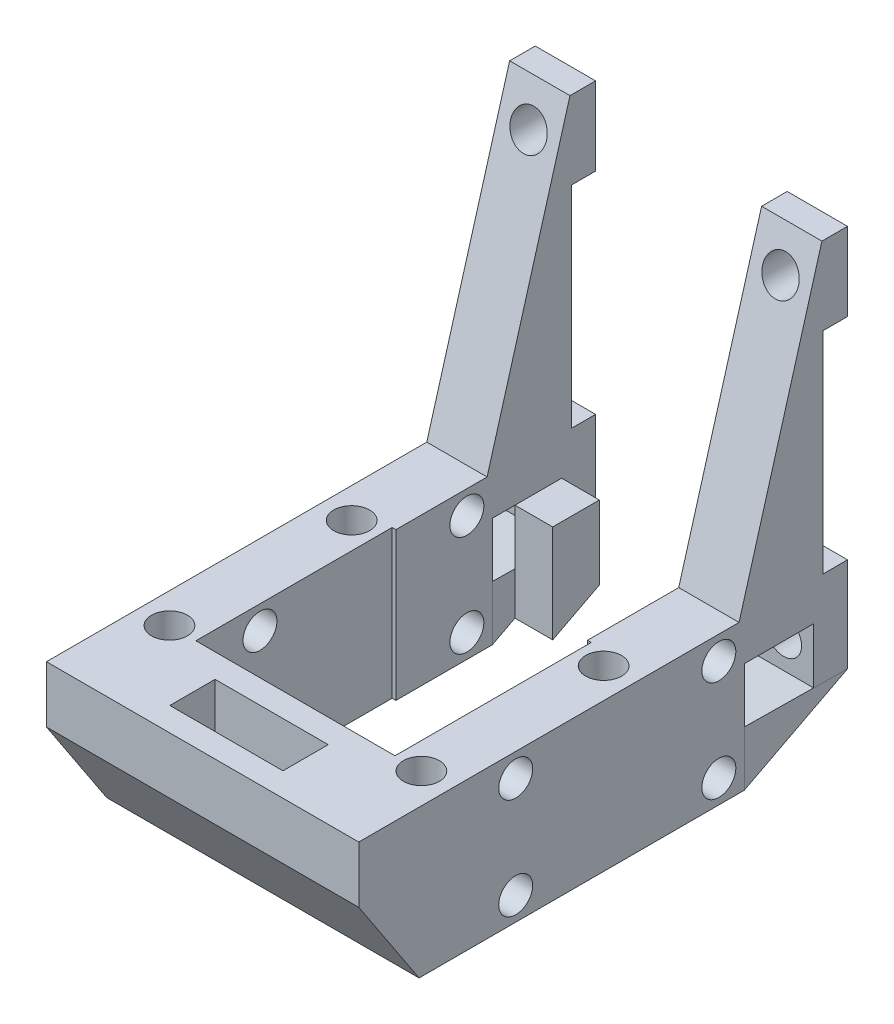
from build123d import *

# Parameters (mm, degrees)
SKETCH1_W             = 7.5
SKETCH1_H             = 7.5
BOSS_EXTRUDE1_DEPTH   = 5.5
BOSS_EXTRUDE1_2_DEPTH = 5.5
BOSS_EXTRUDE1_3_DEPTH = 5.5
BOSS_EXTRUDE1_4_DEPTH = 5.5
BOSS_EXTRUDE2_START   = -5.5
SKETCH2_W             = 8
SKETCH2_H             = 7.5
BOSS_EXTRUDE2_DEPTH   = 50.5
SKETCH3_W             = 41.4
SKETCH3_H             = 7.5
BOSS_EXTRUDE3_DEPTH   = 16
BOSS_EXTRUDE4_DEPTH   = 8
SKETCH5_R             = 2.5
CUT_EXTRUDE1_DEPTH    = 8
SKETCH6_W             = 38.1096
SKETCH6_H             = 12.112327922
BOSS_EXTRUDE6_DEPTH   = 8
SKETCH9_W             = 41.4
SKETCH9_H             = 12.112327922
BOSS_EXTRUDE7_DEPTH   = 8
SKETCH10_R            = 2.25
CUT_EXTRUDE2_DEPTH    = 42.4
BOSS_EXTRUDE8_DEPTH   = 8
BOSS_EXTRUDE9_DEPTH   = 8
SKETCH13_W            = 4.925533285
SKETCH13_H            = 27.926
CUT_EXTRUDE3_DEPTH    = 42.4
BOSS_EXTRUDE10_DEPTH  = 41.4
SKETCH16_W            = 26.4
SKETCH16_H            = 26.013663936
CUT_EXTRUDE5_DEPTH    = 20.612327922
SKETCH17_W            = 25.4
SKETCH17_H            = 5.5
CUT_EXTRUDE6_DEPTH    = 50
SKETCH18_W            = 41.4
SKETCH18_H            = 1.703308899
CUT_EXTRUDE7_DEPTH    = 50
SKETCH19_R            = 2.38125
CUT_EXTRUDE8_DEPTH    = 50
SKETCH21_W            = 10.687091101
SKETCH21_H            = 14.528220305
CUT_EXTRUDE10_DEPTH   = 55
SKETCH22_W            = 8
SKETCH22_H            = 4.5
BOSS_EXTRUDE11_DEPTH  = 7.42786537
SKETCH23_R            = 2.38125
CUT_EXTRUDE11_DEPTH   = 5
SKETCH25_W            = 6.187091101
SKETCH25_H            = 14.528220305
BOSS_EXTRUDE12_DEPTH  = 5
SKETCH26_W            = 3
SKETCH26_H            = 14.528220305
CUT_EXTRUDE12_DEPTH   = 42.4
BOSS_EXTRUDE15_DEPTH  = 8
CUT_EXTRUDE13_DEPTH   = 34.4
SKETCH29_W            = 15
SKETCH29_H            = 6
CUT_EXTRUDE14_DEPTH   = 10
SKETCH30_R            = 2.38125
CUT_EXTRUDE15_DEPTH   = 10
SKETCH31_R            = 2.38125
CUT_EXTRUDE16_DEPTH   = 10


with BuildPart() as part:
    # Sketch1 → Boss-Extrude1 (new body)
    with BuildSketch(Plane(origin=(-474.147028746, -1016.113518437, 5527.294851894), x_dir=(1, 0, 0), z_dir=(0, 0, 1))):
        with Locations((215.351694909, 679.332213979)):
            Rectangle(SKETCH1_W, SKETCH1_H)
    extrude(amount=BOSS_EXTRUDE1_DEPTH)

    # Sketch2 → Boss-Extrude2 (add)
    with BuildSketch(Plane.XY.offset(5532.794851894).offset(BOSS_EXTRUDE2_START)):
        with Locations((-233.145333837, -336.781304458)):
            Rectangle(SKETCH2_W, SKETCH2_H)
        with Locations((-266.545333837, -336.781304458)):
            Rectangle(SKETCH2_W, SKETCH2_H)
    boss_extrude2 = extrude(amount=BOSS_EXTRUDE2_DEPTH)

    # Sketch3 → Boss-Extrude3 (add)
    with BuildSketch(Plane.XY.offset(5577.794851894)):
        with Locations((-249.845333837, -336.781304458)):
            Rectangle(SKETCH3_W, SKETCH3_H)
    extrude(amount=BOSS_EXTRUDE3_DEPTH)



with BuildPart() as body_2:
    # Sketch1 → Boss-Extrude1 2 (new body)
    with BuildSketch(Plane(origin=(-474.147028746, -1016.113518437, 5527.294851894), x_dir=(1, 0, 0), z_dir=(0, 0, 1))):
        with Locations((233.251694909, 679.332213979)):
            Rectangle(SKETCH1_W, SKETCH1_H)
    extrude(amount=BOSS_EXTRUDE1_2_DEPTH)


with BuildPart() as body_3:
    # Sketch1 → Boss-Extrude1 3 (new body)
    with BuildSketch(Plane(origin=(-474.147028746, -1016.113518437, 5527.294851894), x_dir=(1, 0, 0), z_dir=(0, 0, 1))):
        with Locations((233.251694909, 714.758213979)):
            Rectangle(SKETCH1_W, SKETCH1_H)
    extrude(amount=BOSS_EXTRUDE1_3_DEPTH)


with BuildPart() as body_4:
    # Sketch1 → Boss-Extrude1 4 (new body)
    with BuildSketch(Plane(origin=(-474.147028746, -1016.113518437, 5527.294851894), x_dir=(1, 0, 0), z_dir=(0, 0, 1))):
        with Locations((215.351694909, 714.758213979)):
            Rectangle(SKETCH1_W, SKETCH1_H)
    extrude(amount=BOSS_EXTRUDE1_4_DEPTH)


with BuildPart() as part_1:
    add(part.part)

    add(body_4.part)  # Boss-Extrude4 merges body 4
    # Sketch4 → Boss-Extrude4 (add)
    with BuildSketch(Plane.ZY.offset(262.545333837)):
        Polygon((5527.294851894, -333.031304458), (5527.294851894, -294.74397633), (5532.394065696, -294.74397633), (5543.378858785, -333.031304458), align=None)
    boss_extrude4 = extrude(amount=BOSS_EXTRUDE4_DEPTH)

    # Mirror1: Boss-Extrude2, Boss-Extrude4 across plane
    add(boss_extrude2.mirror(Plane.ZY.offset(249.845333837)))
    add(boss_extrude4.mirror(Plane.ZY.offset(249.845333837)))


with BuildPart() as cut_extrude1_tool:
    # Sketch5 → Cut-Extrude1 (new body)
    with BuildSketch(Plane.XY.offset(5532.794851894)):
        with Locations((-258.795333837, -301.355304458)):
            Circle(SKETCH5_R)
        with Locations((-240.895333837, -301.355304458)):
            Circle(SKETCH5_R)
        with Locations((-240.895333837, -336.781304458)):
            Circle(SKETCH5_R)
        with Locations((-258.795333837, -336.781304458)):
            Circle(SKETCH5_R)
    extrude(amount=-CUT_EXTRUDE1_DEPTH)


with BuildPart() as part_2:
    add(part_1.part)

    # Cut-Extrude1: cut by cut_extrude1_tool
    add(cut_extrude1_tool.part, mode=Mode.SUBTRACT)

    # Sketch6 → Boss-Extrude6 (add)
    with BuildSketch(Plane.ZY.offset(270.545333837)):
        with Locations((5558.740051894, -346.587468419)):
            Rectangle(SKETCH6_W, SKETCH6_H)
    boss_extrude6 = extrude(amount=-BOSS_EXTRUDE6_DEPTH)

    # Mirror2: Boss-Extrude6 across plane
    add(boss_extrude6.mirror(Plane.ZY.offset(249.845333837)))

    # Sketch9 → Boss-Extrude7 (add)
    with BuildSketch(Plane.XY.offset(5577.794851894)):
        with Locations((-249.845333837, -346.587468419)):
            Rectangle(SKETCH9_W, SKETCH9_H)
    extrude(amount=BOSS_EXTRUDE7_DEPTH)

    # Sketch10 → Cut-Extrude2 (cut, through all)
    with BuildSketch(Plane.ZY.offset(270.545333837)):
        with Locations((5546.061207304, -349.537271609)):
            Circle(SKETCH10_R)
        with Locations((5572.989599872, -349.537271609)):
            Circle(SKETCH10_R)
        with Locations((5546.061207304, -336.137665229)):
            Circle(SKETCH10_R)
        with Locations((5572.989599872, -336.137665229)):
            Circle(SKETCH10_R)
    extrude(amount=-CUT_EXTRUDE2_DEPTH, mode=Mode.SUBTRACT)

    # Sketch11 → Boss-Extrude8 (add)
    with BuildSketch(Plane.ZY.offset(270.545333837)):
        Polygon((5527.294851894, -340.372465198), (5539.685251894, -352.64363238), (5539.685251894, -340.531304458), align=None)
    extrude(amount=-BOSS_EXTRUDE8_DEPTH)



with BuildPart() as body_2_1:
    add(body_2.part)

    # Cut-Extrude1: cut by cut_extrude1_tool
    add(cut_extrude1_tool.part, mode=Mode.SUBTRACT)


with BuildPart() as body_3_1:
    add(body_3.part)

    # Cut-Extrude1: cut by cut_extrude1_tool
    add(cut_extrude1_tool.part, mode=Mode.SUBTRACT)


with BuildPart() as part_3:
    add(part_2.part)

    add(body_2_1.part)  # Boss-Extrude9 merges body 2
    # Sketch12 → Boss-Extrude9 (add)
    with BuildSketch(Plane(origin=(-229.145333837, 0, 0), x_dir=(0, 0, -1), z_dir=(1, 0, 0))):
        Polygon((-5539.685251894, -352.64363238), (-5527.294851894, -340.531304458), (-5539.685251894, -340.531304458), align=None)
    extrude(amount=-BOSS_EXTRUDE9_DEPTH)

    # Sketch13 → Cut-Extrude3 (cut, through all)
    with BuildSketch(Plane.ZY.offset(270.545333837)):
        with Locations((5529.757618536, -319.068304458)):
            Rectangle(SKETCH13_W, SKETCH13_H)
    extrude(amount=-CUT_EXTRUDE3_DEPTH, mode=Mode.SUBTRACT)

    # Sketch14 → Boss-Extrude10 (add)
    with BuildSketch(Plane.ZY.offset(270.545333837)):
        Polygon((5585.794851894, -352.64363238), (5593.794851894, -340.531304458), (5585.794851894, -340.531304458), align=None)
    extrude(amount=-BOSS_EXTRUDE10_DEPTH)

    # Sketch16 → Cut-Extrude5 (cut, through all)
    with BuildSketch(Plane(origin=(0, -333.031304458, 0), x_dir=(1, 0, 0), z_dir=(0, 1, 0))):
        with Locations((-249.845333837, -5568.481626817)):
            Rectangle(SKETCH16_W, SKETCH16_H)
    extrude(amount=-CUT_EXTRUDE5_DEPTH, mode=Mode.SUBTRACT)


with BuildPart() as cut_extrude6_tool:
    # Sketch17 → Cut-Extrude6 (new body)
    with BuildSketch(Plane(origin=(0, -297.605304458, 0), x_dir=(1, 0, 0), z_dir=(0, 1, 0))):
        with Locations((-249.845333837, -5530.044851894)):
            Rectangle(SKETCH17_W, SKETCH17_H)
    extrude(amount=-CUT_EXTRUDE6_DEPTH)


with BuildPart() as part_4:
    add(part_3.part)

    # Cut-Extrude6: cut by cut_extrude6_tool
    add(cut_extrude6_tool.part, mode=Mode.SUBTRACT)

    # Sketch18 → Cut-Extrude7 (cut)
    with BuildSketch(Plane(origin=(0, -294.74397633, 0), x_dir=(1, 0, 0), z_dir=(0, 1, 0))):
        with Locations((-249.845333837, -5528.146506344)):
            Rectangle(SKETCH18_W, SKETCH18_H)
    extrude(amount=-CUT_EXTRUDE7_DEPTH, mode=Mode.SUBTRACT)

    # Sketch19 → Cut-Extrude8 (cut)
    with BuildSketch(Plane(origin=(0, 0, 5528.998160793), x_dir=(-1, 0, 0), z_dir=(0, 0, -1))):
        with Locations((233.145333837, -299.924640394)):
            Circle(SKETCH19_R)
    cut_extrude8 = extrude(amount=-CUT_EXTRUDE8_DEPTH, mode=Mode.SUBTRACT)

    # Sketch21 → Cut-Extrude10 (cut)
    with BuildSketch(Plane.ZY.offset(270.545333837)):
        with Locations((5534.341706344, -345.379522228)):
            Rectangle(SKETCH21_W, SKETCH21_H)
    extrude(amount=-CUT_EXTRUDE10_DEPTH, mode=Mode.SUBTRACT)

    # Sketch22 → Boss-Extrude11 (add)
    with BuildSketch(Plane.XZ.offset(338.115412075)):
        with Locations((-266.545333837, 5531.248160793)):
            Rectangle(SKETCH22_W, SKETCH22_H)
    boss_extrude11 = extrude(amount=BOSS_EXTRUDE11_DEPTH)

    # Mirror5: Boss-Extrude11 across plane
    add(boss_extrude11.mirror(Plane.ZY.offset(249.845333837)))

    # Sketch23 → Cut-Extrude11 (cut)
    with BuildSketch(Plane(origin=(0, 0, 5528.998160793), x_dir=(-1, 0, 0), z_dir=(0, 0, -1))):
        with Locations((233.118864035, -341.469886082)):
            Circle(SKETCH23_R)
    cut_extrude11 = extrude(amount=-CUT_EXTRUDE11_DEPTH, mode=Mode.SUBTRACT)

    # Sketch26 → Cut-Extrude12 (cut, through all)
    with BuildSketch(Plane.ZY.offset(270.545333837)):
        with Locations((5541.185251894, -345.379522228)):
            Rectangle(SKETCH26_W, SKETCH26_H)
    extrude(amount=-CUT_EXTRUDE12_DEPTH, mode=Mode.SUBTRACT)

    # Mirror6: Cut-Extrude11 across plane
    add(cut_extrude11.mirror(Plane.ZY.offset(249.845333837)), mode=Mode.SUBTRACT)

    # Sketch29 → Cut-Extrude14 (cut)
    with BuildSketch(Plane(origin=(0, -333.031304458, 0), x_dir=(1, 0, 0), z_dir=(0, 1, 0))):
        with Locations((-249.845333837, -5587.64165534)):
            Rectangle(SKETCH29_W, SKETCH29_H)
    extrude(amount=-CUT_EXTRUDE14_DEPTH, mode=Mode.SUBTRACT)

    # Sketch30 → Cut-Extrude15 (cut)
    with BuildSketch(Plane(origin=(0, -333.031304458, 0), x_dir=(1, 0, 0), z_dir=(0, 1, 0))):
        with Locations((-266.545333837, -5557.335586136)):
            Circle(SKETCH30_R)
    cut_extrude15 = extrude(amount=-CUT_EXTRUDE15_DEPTH, mode=Mode.SUBTRACT)

    # Sketch31 → Cut-Extrude16 (cut)
    with BuildSketch(Plane(origin=(0, -333.031304458, 0), x_dir=(1, 0, 0), z_dir=(0, 1, 0))):
        with Locations((-233.145333837, -5581.488458785)):
            Circle(SKETCH31_R)
    cut_extrude16 = extrude(amount=-CUT_EXTRUDE16_DEPTH, mode=Mode.SUBTRACT)

    # Mirror12: Cut-Extrude15, Cut-Extrude16 across plane
    add(cut_extrude15.mirror(Plane.ZY.offset(249.845333837)), mode=Mode.SUBTRACT)
    add(cut_extrude16.mirror(Plane.ZY.offset(249.845333837)), mode=Mode.SUBTRACT)

    # Mirror13: Cut-Extrude8 across plane
    add(cut_extrude8.mirror(Plane.ZY.offset(249.845333837)), mode=Mode.SUBTRACT)


with BuildPart() as body_3_2:
    add(body_3_1.part)

    # Cut-Extrude6: cut by cut_extrude6_tool
    add(cut_extrude6_tool.part, mode=Mode.SUBTRACT)


with BuildPart() as body_2_2:
    # Sketch25 → Boss-Extrude12 (new body)
    with BuildSketch(Plane(origin=(-262.545333837, 0, 0), x_dir=(0, 0, -1), z_dir=(1, 0, 0))):
        with Locations((-5536.591706344, -345.379522228)):
            Rectangle(SKETCH25_W, SKETCH25_H)
    extrude(amount=BOSS_EXTRUDE12_DEPTH)

    # Sketch28 → Cut-Extrude13 (cut, through all)
    with BuildSketch(Plane.ZY.offset(262.545333837)):
        Polygon((5533.498160793, -347.87771045), (5539.685251894, -351.08734371), (5543.378858785, -359.563611735), (5533.262204425, -359.563611735), align=None)
    extrude(amount=-CUT_EXTRUDE13_DEPTH, mode=Mode.SUBTRACT)


with BuildPart() as body_3_2_1:
    # Sketch27 → Boss-Extrude15 (new body)
    with BuildSketch(Plane.ZY.offset(270.545333837)):
        Polygon((5542.685251894, -352.64363238), (5528.998160793, -345.543277445), (5542.685251894, -345.379522228), align=None)
    extrude(amount=-BOSS_EXTRUDE15_DEPTH)


with BuildPart() as body_4_2:
    # Mirror11: mirrored copy
    add(body_2_2.part.mirror(Plane.ZY.offset(249.845333837)))


with BuildPart() as body_5:
    # Mirror11 2: mirrored copy
    add(body_3_2_1.part.mirror(Plane.ZY.offset(249.845333837)))


solid = Compound([part_4.part, body_2_2.part, body_3_2_1.part, body_4_2.part, body_5.part])
